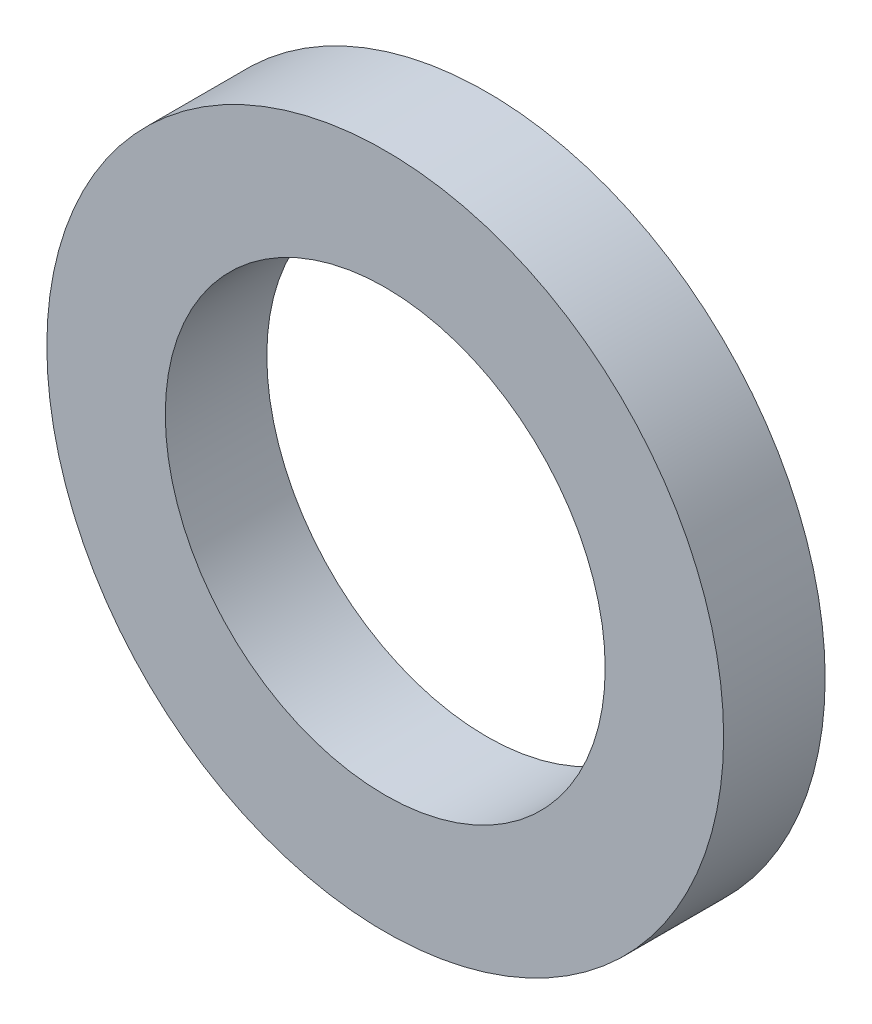
from build123d import *

# Parameters (mm, degrees)
SKETCH_1_R      = 10
SKETCH_1_R_2    = 6.5
EXTRUDE_1_DEPTH = 3


with BuildPart() as part:
    # 草图1 → 凸台-拉伸1 (new body)
    with BuildSketch(Plane.XY):
        Circle(SKETCH_1_R)
        Circle(SKETCH_1_R_2, mode=Mode.SUBTRACT)
    extrude(amount=EXTRUDE_1_DEPTH)


solid = part.part
